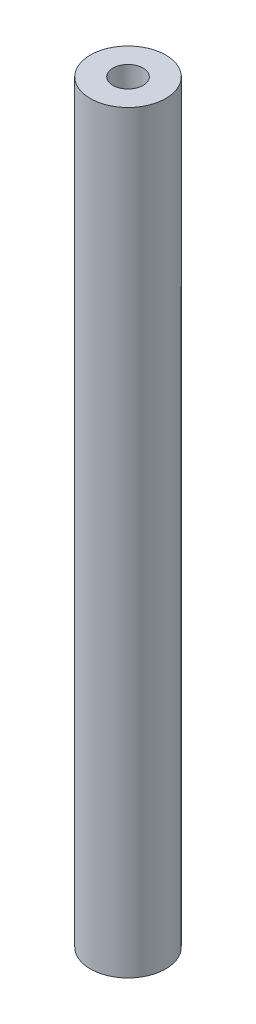
from build123d import *

# Parameters (mm, degrees)
SKETCH1_W = 0.9
SKETCH1_H = 30


with BuildPart() as part:
    # Sketch1 → Revolve1 (revolve)
    with BuildSketch(Plane.XY):
        with Locations((1.05, 15)):
            Rectangle(SKETCH1_W, SKETCH1_H)
    revolve(axis=Axis((0, 0, 0), (0, 1, 0)))


solid = part.part
